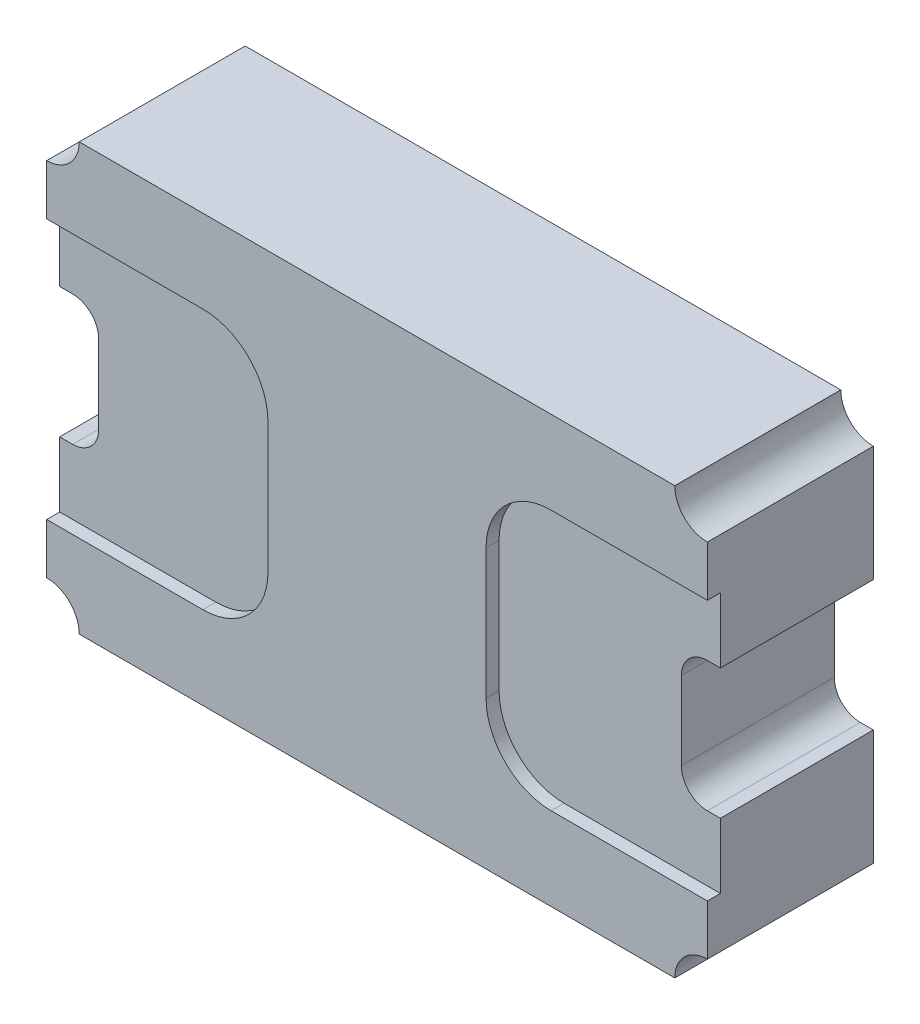
from build123d import *

# Parameters (mm, degrees)
IZIM1_W                     = 5.075
IZIM1_H                     = 3.275
Y_KSEKLIK_EKSTR_ZYON1_DEPTH = 1.275
IZIM2_W                     = 0.1
IZIM2_H                     = 2
KES_EKSTR_ZYON1_DEPTH       = 1.7
IZIM3_W                     = 0.1
IZIM3_H                     = 2
KES_EKSTR_ZYON2_DEPTH       = 1.7
KES_EKSTR_ZYON3_DEPTH       = 1.7
IZIM5_R                     = 0.25
KES_EKSTR_ZYON4_DEPTH       = 1.7
RADYUS1_R                   = 0.5


with BuildPart() as part:
    # Çizim1 → Yükseklik-Ekstrüzyon1 (new body)
    with BuildSketch(Plane.XY):
        Rectangle(IZIM1_W, IZIM1_H)
    extrude(amount=Y_KSEKLIK_EKSTR_ZYON1_DEPTH)

    # Çizim2 → Kes-Ekstrüzyon1 (cut)
    with BuildSketch(Plane(origin=(2.5375, 0, 0), x_dir=(0, 0, -1), z_dir=(1, 0, 0))):
        with Locations((-1.225, 0)):
            Rectangle(IZIM2_W, IZIM2_H)
    extrude(amount=-KES_EKSTR_ZYON1_DEPTH, mode=Mode.SUBTRACT)

    # Çizim3 → Kes-Ekstrüzyon2 (cut)
    with BuildSketch(Plane.ZY.offset(2.5375)):
        with Locations((1.225, 0)):
            Rectangle(IZIM3_W, IZIM3_H)
    extrude(amount=-KES_EKSTR_ZYON2_DEPTH, mode=Mode.SUBTRACT)

    # Çizim4 → Kes-Ekstrüzyon3 (cut)
    with BuildSketch(Plane(origin=(0, 0, 0), x_dir=(-1, 0, 0), z_dir=(0, 0, -1))):
        with BuildLine():
            Line((-2.2375, -0.3), (-2.2375, 0.3))
            ThreePointArc((-2.2375, 0.3), (-2.296078644, 0.441421356), (-2.4375, 0.5))
            Line((-2.4375, 0.5), (-2.5375, 0.5))
            Line((-2.5375, 0.5), (-2.5375, -0.5))
            Line((-2.5375, -0.5), (-2.4375, -0.5))
            ThreePointArc((-2.4375, -0.5), (-2.296078644, -0.441421356), (-2.2375, -0.3))
        make_face()
        with BuildLine():
            Line((2.2375, -0.3), (2.2375, 0.3))
            ThreePointArc((2.2375, 0.3), (2.296078644, 0.441421356), (2.4375, 0.5))
            Line((2.4375, 0.5), (2.5375, 0.5))
            Line((2.5375, 0.5), (2.5375, -0.5))
            Line((2.5375, -0.5), (2.4375, -0.5))
            ThreePointArc((2.4375, -0.5), (2.296078644, -0.441421356), (2.2375, -0.3))
        make_face()
    extrude(amount=-KES_EKSTR_ZYON3_DEPTH, mode=Mode.SUBTRACT)

    # Çizim5 → Kes-Ekstrüzyon4 (cut)
    with BuildSketch(Plane(origin=(0, 0, 0), x_dir=(-1, 0, 0), z_dir=(0, 0, -1))):
        with Locations((-2.5375, 1.6375)):
            Circle(IZIM5_R)
        with Locations((2.5375, 1.6375)):
            Circle(IZIM5_R)
        with Locations((2.5375, -1.6375)):
            Circle(IZIM5_R)
        with Locations((-2.5375, -1.6375)):
            Circle(IZIM5_R)
    extrude(amount=-KES_EKSTR_ZYON4_DEPTH, mode=Mode.SUBTRACT)

    # Radyus1
    radyus1_edges = [part.edges().sort_by_distance(p)[0] for p in [
        (0.8375, -1, 1.225),
        (0.8375, 1, 1.225),
        (-0.8375, 1, 1.225),
        (-0.8375, -1, 1.225),
    ]]
    fillet(radyus1_edges, radius=RADYUS1_R)


solid = part.part
